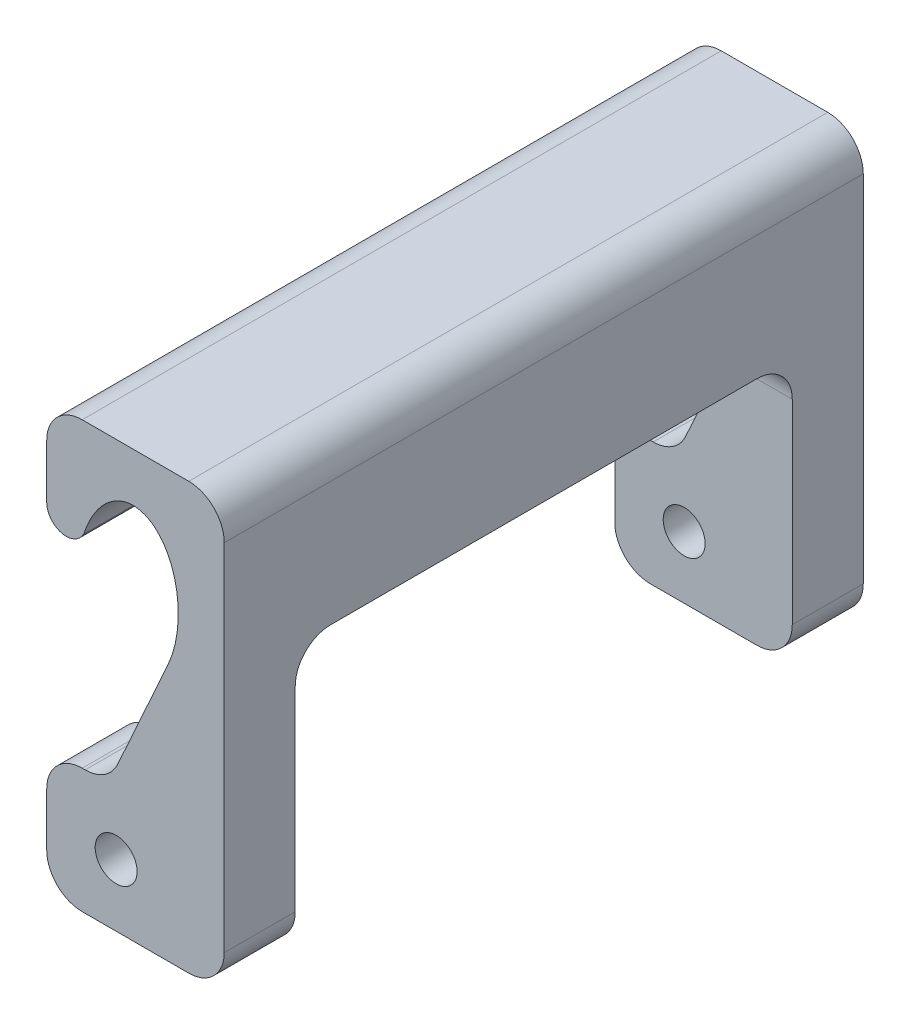
from build123d import *

# Parameters (mm, degrees)
SKETCH1_R           = 1.5
BOSS_EXTRUDE1_DEPTH = 45.72
CUT_EXTRUDE1_DEPTH  = 25.4


with BuildPart() as part:
    # Sketch1 → Boss-Extrude1 (new body)
    with BuildSketch(Plane.XY):
        with BuildLine():
            add(Edge.make_bspline(
                [(8.677884321, 18.376352753), (9.611503438, 20.442753269), (9.364466551, 22.79145978)],
                knots=[4.222526815, 4.222526815, 4.222526815, 5.034979768, 5.034979768, 5.034979768], degree=2, weights=[1, 0.918618451, 1]))
            Line((8.677884321, 18.376352753), (5.066951203, 10.384192012))
            ThreePointArc((5.066951203, 10.384192012), (4.129783184, 9.29599528), (2.752240497, 8.89))
            Line((2.752240497, 8.89), (2.54, 8.89))
            ThreePointArc((2.54, 8.89), (0.743948776, 8.146051224), (0, 6.35))
            Line((0, 6.35), (0, 2.54))
            ThreePointArc((0, 2.54), (0.743948776, 0.743948776), (2.54, 0))
            Line((2.54, 0), (10.16, 0))
            ThreePointArc((10.16, 0), (11.956051224, 0.743948776), (12.7, 2.54))
            Line((12.7, 2.54), (12.7, 27.94))
            ThreePointArc((12.7, 27.94), (11.956051224, 29.736051224), (10.16, 30.48))
            Line((10.16, 30.48), (2.54, 30.48))
            ThreePointArc((2.54, 30.48), (0.743948776, 29.736051224), (0, 27.94))
            Line((0, 27.94), (0, 24.08))
            ThreePointArc((0, 24.08), (1.01383309, 22.739069096), (2.58032425, 23.349035215))
            ThreePointArc((2.58032425, 23.349035215), (2.620527336, 23.41287828), (2.661984223, 23.475914394))
            add(Edge.make_bspline(
                [(6.406345811, 26.98329616), (3.861791417, 27.243144961), (2.661984223, 23.475914394)],
                knots=[0, 0, 0, 1.248205539, 1.248205539, 1.248205539], degree=2, weights=[1, 0.81148776, 1]))
            add(Edge.make_bspline(
                [(9.364466551, 22.79145978), (8.950900204, 26.723447359), (6.406345811, 26.98329616)],
                knots=[5.034979768, 5.034979768, 5.034979768, 6.283185307, 6.283185307, 6.283185307], degree=2, weights=[1, 0.81148776, 1]))
        make_face()
        with Locations((4.965459901, 4.445)):
            Circle(SKETCH1_R, mode=Mode.SUBTRACT)
    extrude(amount=BOSS_EXTRUDE1_DEPTH)

    # Sketch2 → Cut-Extrude1 (cut)
    with BuildSketch(Plane(origin=(12.7, 0, 0), x_dir=(0, 0, -1), z_dir=(1, 0, 0))):
        with BuildLine():
            Line((-40.64, 0), (-5.08, 0))
            Line((-5.08, 0), (-5.08, 16.51))
            ThreePointArc((-5.08, 16.51), (-5.823948776, 18.306051224), (-7.62, 19.05))
            Line((-7.62, 19.05), (-38.1, 19.05))
            ThreePointArc((-38.1, 19.05), (-39.896051224, 18.306051224), (-40.64, 16.51))
            Line((-40.64, 16.51), (-40.64, 0))
        make_face()
    extrude(amount=-CUT_EXTRUDE1_DEPTH, mode=Mode.SUBTRACT)


solid = part.part
